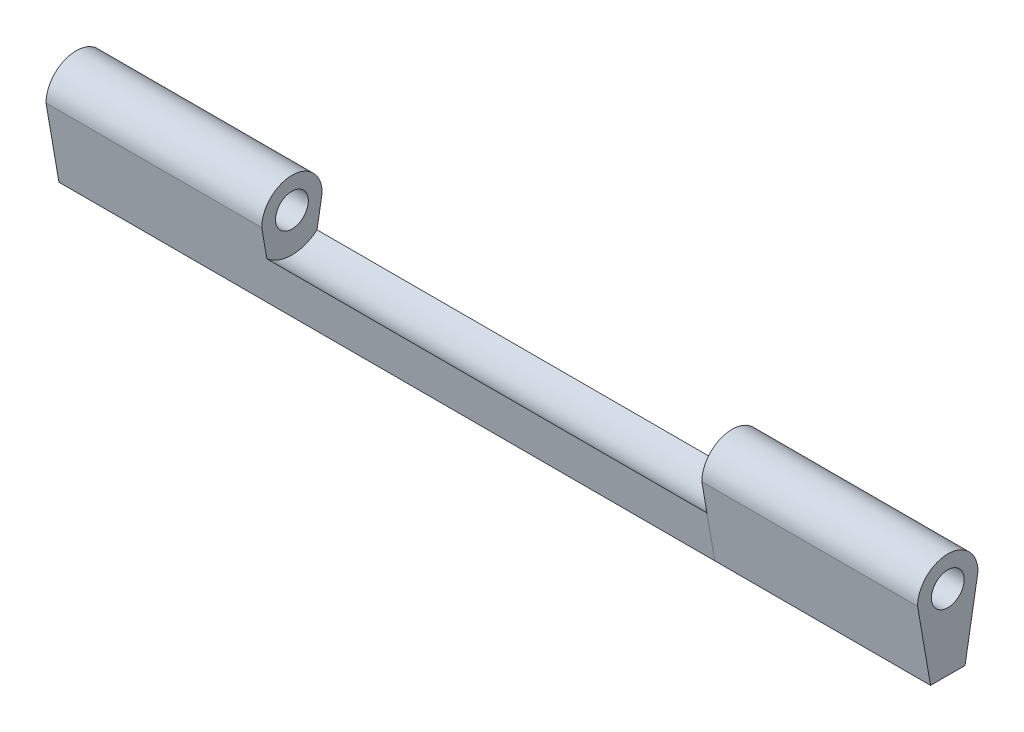
from build123d import *

# Parameters (mm, degrees)
SKETCH1_R           = 1.9
BOSS_EXTRUDE1_DEPTH = 25
BOSS_EXTRUDE2_DEPTH = 51
SKETCH3_R           = 1.51
BOSS_EXTRUDE3_DEPTH = 25
SKETCH7_R           = 1.9
CUT_EXTRUDE4_DEPTH  = 102


with BuildPart() as part:
    # Sketch1 → Boss-Extrude1 (new body)
    with BuildSketch(Plane(origin=(0, 0, 0), x_dir=(0, 0, -1), z_dir=(1, 0, 0))):
        with BuildLine():
            Line((2, -8.7), (3.5, 0))
            ThreePointArc((3.5, 0), (0, 3.5), (-3.5, 0))
            Line((-3.5, 0), (-2, -8.7))
            Line((-2, -8.7), (2, -8.7))
        make_face()
        Circle(SKETCH1_R, mode=Mode.SUBTRACT)
    extrude(amount=BOSS_EXTRUDE1_DEPTH)

    # Sketch2 → Boss-Extrude2 (add)
    with BuildSketch(Plane(origin=(25, 0, 0), x_dir=(0, 0, -1), z_dir=(1, 0, 0))):
        with BuildLine():
            Line((-2, -8.7), (2, -8.7))
            Line((2, -8.7), (2.907884559, -3.434269557))
            ThreePointArc((2.907884559, -3.434269557), (0, -4.5), (-2.907884559, -3.434269557))
            Line((-2.907884559, -3.434269557), (-2, -8.7))
        make_face()
    extrude(amount=BOSS_EXTRUDE2_DEPTH)


with BuildPart() as body_2:
    # Sketch3 → Boss-Extrude3 (new body)
    with BuildSketch(Plane(origin=(76, 0, 0), x_dir=(0, 0, -1), z_dir=(1, 0, 0))):
        with BuildLine():
            Line((-3.5, 0), (-2, -8.7))
            Line((-2, -8.7), (2, -8.7))
            Line((2, -8.7), (3.5, 0))
            ThreePointArc((3.5, 0), (0, 3.5), (-3.5, 0))
        make_face()
        Circle(SKETCH3_R, mode=Mode.SUBTRACT)
    extrude(amount=BOSS_EXTRUDE3_DEPTH)

    # Sketch7 → Cut-Extrude4 (cut, through all)
    with BuildSketch(Plane(origin=(101, 0, 0), x_dir=(0, 0, -1), z_dir=(1, 0, 0))):
        Circle(SKETCH7_R)
    extrude(amount=-CUT_EXTRUDE4_DEPTH, mode=Mode.SUBTRACT)


solid = Compound([part.part, body_2.part])
